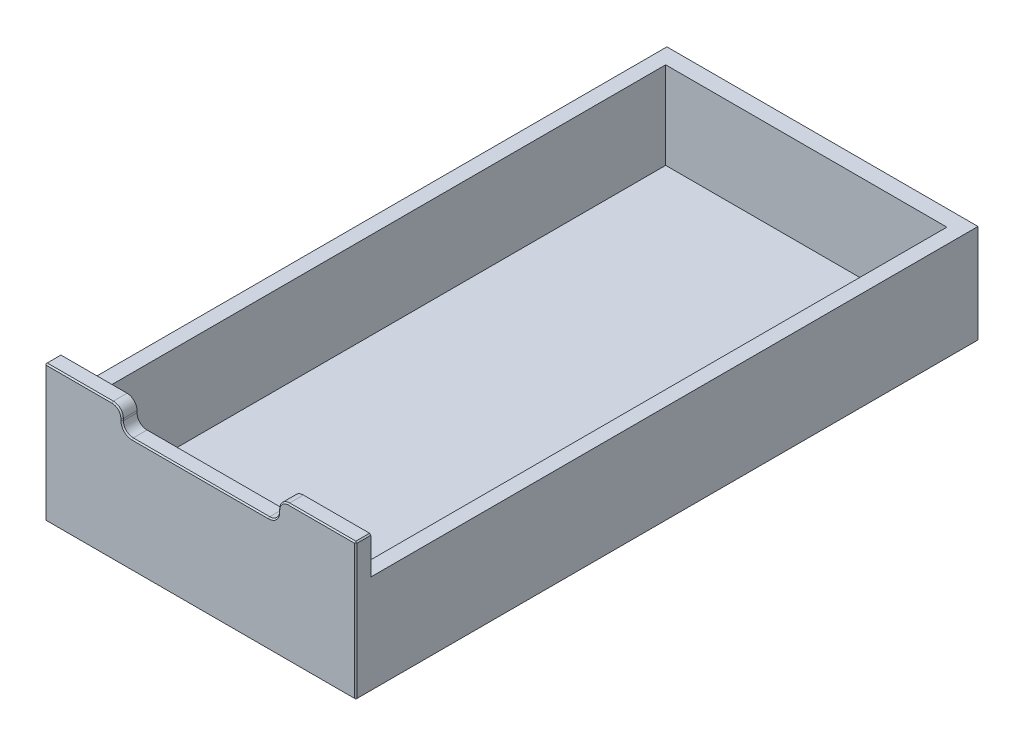
from build123d import *

# Parameters (mm, degrees)
SKETCH1_W           = 250
SKETCH1_H           = 500
BOSS_EXTRUDE1_DEPTH = 110
SKETCH2_W           = 226
SKETCH2_H           = 474
CUT_EXTRUDE1_DEPTH  = 100
SKETCH3_W           = 226
SKETCH3_H           = 474
CUT_EXTRUDE2_DEPTH  = 7
SKETCH4_W           = 531.711239379
SKETCH4_H           = 96.104903681
CUT_EXTRUDE3_DEPTH  = 251
SKETCH5_W           = 125.68494841
SKETCH5_H           = 51.126080709
CUT_EXTRUDE4_DEPTH  = 15
FILLET1_R           = 8
CHAMFER1_SIZE       = 1
CHAMFER2_SIZE       = 1


with BuildPart() as part:
    # Sketch1 → Boss-Extrude1 (new body)
    with BuildSketch(Plane(origin=(0, 0, 0), x_dir=(1, 0, 0), z_dir=(0, 1, 0))):
        Rectangle(SKETCH1_W, SKETCH1_H)
    extrude(amount=BOSS_EXTRUDE1_DEPTH)

    # Sketch2 → Cut-Extrude1 (cut)
    with BuildSketch(Plane(origin=(0, 110, 0), x_dir=(1, 0, 0), z_dir=(0, 1, 0))):
        Rectangle(SKETCH2_W, SKETCH2_H)
    extrude(amount=-CUT_EXTRUDE1_DEPTH, mode=Mode.SUBTRACT)

    # Sketch3 → Cut-Extrude2 (cut)
    with BuildSketch(Plane.XZ):
        Rectangle(SKETCH3_W, SKETCH3_H)
    extrude(amount=-CUT_EXTRUDE2_DEPTH, mode=Mode.SUBTRACT)

    # Sketch4 → Cut-Extrude3 (cut, through all)
    with BuildSketch(Plane(origin=(125, 0, 0), x_dir=(0, 0, -1), z_dir=(1, 0, 0))):
        with Locations((27.855619689, 128.05245184)):
            Rectangle(SKETCH4_W, SKETCH4_H)
    extrude(amount=-CUT_EXTRUDE3_DEPTH, mode=Mode.SUBTRACT)

    # Sketch5 → Cut-Extrude4 (cut)
    with BuildSketch(Plane.XY.offset(250)):
        with Locations((0, 117.975615041)):
            Rectangle(SKETCH5_W, SKETCH5_H)
    extrude(amount=-CUT_EXTRUDE4_DEPTH, mode=Mode.SUBTRACT)

    # Fillet1
    fillet1_edges = [part.edges().sort_by_distance(p)[0] for p in [
        (62.842474205, 110, 244),
        (62.842474205, 92.412574686, 244),
        (-62.842474205, 110, 244),
        (-62.842474205, 92.412574686, 244),
    ]]
    fillet(fillet1_edges, radius=FILLET1_R)

    # Chamfer1
    chamfer1_edges = [part.edges().sort_by_distance(p)[0] for p in [
        (-97.921237103, 110, 250),
        (0, 0, 250),
        (125, 55, 250),
        (-125, 55, 250),
        (62.842474205, 101.206287343, 250),
        (0, 92.412574686, 250),
        (97.921237103, 110, 250),
        (-62.842474205, 101.206287343, 250),
        (-65.185619956, 107.656854249, 250),
        (65.185619956, 107.656854249, 250),
        (60.499328455, 94.755720436, 250),
        (-60.499328455, 94.755720436, 250),
    ]]
    chamfer(chamfer1_edges, length=CHAMFER1_SIZE)

    # Chamfer2
    chamfer2_edges = [part.edges().sort_by_distance(p)[0] for p in [
        (125, 110, 243.5),
        (125, 0, -0.5),
        (-125, 110, 243.5),
        (-125, 0, -0.5),
    ]]
    chamfer(chamfer2_edges, length=CHAMFER2_SIZE)


solid = part.part
